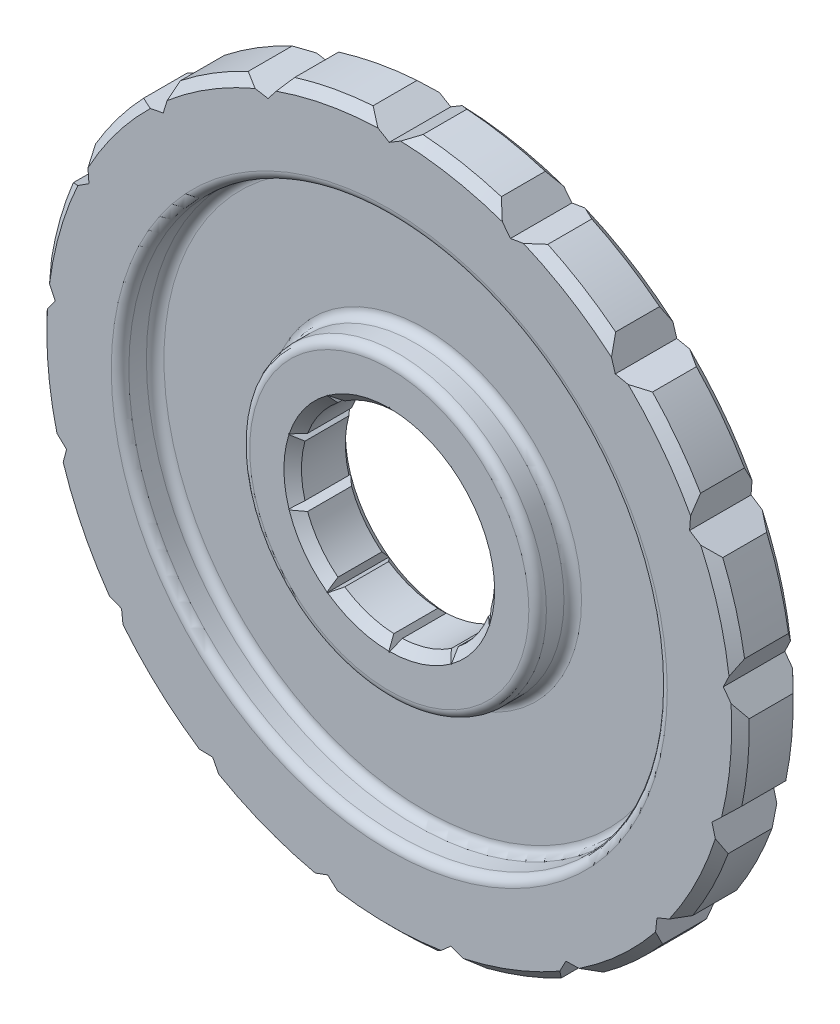
from build123d import *

# Parameters (mm, degrees)
SKETCH1_R           = 40
SKETCH1_R_2         = 11
BOSS_EXTRUDE1_DEPTH = 7
CHAMFER1_SIZE       = 1
CUT_EXTRUDE1_DEPTH  = 7
SKETCH3_R           = 30.662461865
SKETCH3_R_2         = 16.896517562
CUT_EXTRUDE2_DEPTH  = 4
FILLET1_R           = 1


with BuildPart() as part:
    # Sketch1 → Boss-Extrude1 (new body)
    with BuildSketch(Plane.XY):
        Circle(SKETCH1_R)
        Circle(SKETCH1_R_2, mode=Mode.SUBTRACT)
    extrude(amount=BOSS_EXTRUDE1_DEPTH)

    # Chamfer1
    chamfer1_edges = [part.edges().sort_by_distance(p)[0] for p in [
        (-40, 0, 0),
        (-40, 0, 7),
        (-11, 0, 0),
        (-11, 0, 7),
    ]]
    chamfer(chamfer1_edges, length=CHAMFER1_SIZE)

    # Sketch2 → Cut-Extrude1 (cut)
    with BuildSketch(Plane.XY.offset(7)):
        Polygon((0, 12.103252956), (-0.886988553, 10.050388397), (0.886988553, 10.050388397), align=None)
        Polygon((6.625058893, 7.609576223), (7.114113593, 9.791737329), (5.189881267, 8.652293804), align=None)
        Polygon((9.832581913, 2.262164572), (11.510877593, 3.740110851), (9.28439284, 3.949317058), align=None)
        Polygon((9.28439284, -3.949317058), (11.510877593, -3.740110851), (9.832581913, -2.262164572), align=None)
        Polygon((5.189881267, -8.652293804), (7.114113593, -9.791737329), (6.625058893, -7.609576223), align=None)
        Polygon((-0.886988553, -10.050388397), (0, -12.103252956), (0.886988553, -10.050388397), align=None)
        Polygon((-6.625058893, -7.609576223), (-7.114113593, -9.791737329), (-5.189881267, -8.652293804), align=None)
        Polygon((-9.832581913, -2.262164572), (-11.510877593, -3.740110851), (-9.28439284, -3.949317058), align=None)
        Polygon((-9.28439284, 3.949317058), (-11.510877593, 3.740110851), (-9.832581913, 2.262164572), align=None)
        Polygon((-5.189881267, 8.652293804), (-7.114113593, 9.791737329), (-6.625058893, 7.609576223), align=None)
        Polygon((-4.96114504, 41.161442774), (0, 38.208566053), (4.96114504, 41.161442774), align=None)
        Polygon((19.495358146, 36.589730008), (10.243098194, 40.174074609), (13.802526064, 35.62842677), align=None)
        Polygon((31.396615107, 27.076371455), (24.063954259, 33.760975056), (25.7409445, 28.236471027), align=None)
        Polygon((39.057585223, 13.906198901), (34.634839957, 22.788268746), (34.202905746, 17.031023409), align=None)
        Polygon((41.443612029, -1.142082872), (40.528098602, 8.737880468), (38.045575046, 3.525441707), align=None)
        Polygon((38.232449384, -16.036120024), (40.947812956, -6.492606986), (36.749978619, -10.456270432), align=None)
        Polygon((29.857782596, -28.764390308), (35.83729827, -20.84623189), (30.49109394, -23.02580531), align=None)
        Polygon((17.450656821, -37.607870291), (25.886757872, -32.384457664), (20.114218068, -32.48557759), align=None)
        Polygon((2.686723144, -41.372199), (12.44006738, -39.548982982), (7.020805589, -37.557992608), align=None)
        Polygon((-12.44006738, -39.548982982), (-2.686723144, -41.372199), (-7.020805589, -37.557992608), align=None)
        Polygon((-25.886757872, -32.384457664), (-17.450656821, -37.607870291), (-20.114218068, -32.48557759), align=None)
        Polygon((-35.83729827, -20.84623189), (-29.857782596, -28.764390308), (-30.49109394, -23.02580531), align=None)
        Polygon((-40.947812956, -6.492606986), (-38.232449384, -16.036120024), (-36.749978619, -10.456270432), align=None)
        Polygon((-40.528098602, 8.737880468), (-41.443612029, -1.142082872), (-38.045575046, 3.525441707), align=None)
        Polygon((-34.634839957, 22.788268746), (-39.057585223, 13.906198901), (-34.202905746, 17.031023409), align=None)
        Polygon((-24.063954259, 33.760975056), (-31.396615107, 27.076371455), (-25.7409445, 28.236471027), align=None)
        Polygon((-10.243098194, 40.174074609), (-19.495358146, 36.589730008), (-13.802526064, 35.62842677), align=None)
    extrude(amount=-CUT_EXTRUDE1_DEPTH, mode=Mode.SUBTRACT)

    # Sketch3 → Cut-Extrude2 (cut)
    with BuildSketch(Plane.XY.offset(7)):
        Circle(SKETCH3_R)
        Circle(SKETCH3_R_2, mode=Mode.SUBTRACT)
    extrude(amount=-CUT_EXTRUDE2_DEPTH, mode=Mode.SUBTRACT)

    # Fillet1
    fillet1_edges = [part.edges().sort_by_distance(p)[0] for p in [
        (-30.662461865, 0, 3),
        (-16.896517562, 0, 3),
        (-30.662461865, 0, 7),
        (-16.896517562, 0, 7),
    ]]
    fillet(fillet1_edges, radius=FILLET1_R)


solid = part.part
